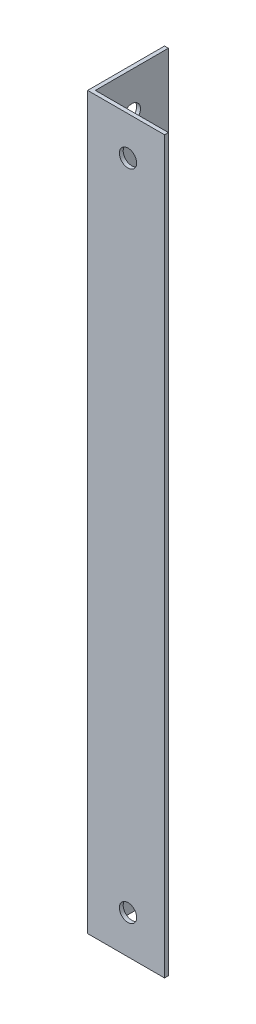
from build123d import *

# Parameters (mm, degrees)
EXTRUDE_1_DEPTH     = 190
SKETCH_2_R          = 2.25
CUT_EXTRUDE_1_DEPTH = 2
SKETCH_3_R          = 2.25
CUT_EXTRUDE_2_DEPTH = 2


with BuildPart() as part:
    # Эскиз1 → Бобышка-Вытянуть1 (new body)
    with BuildSketch(Plane(origin=(0, 0, 0), x_dir=(1, 0, 0), z_dir=(0, 1, 0))):
        Polygon((0, 0), (0, 20), (1, 20), (1, 1), (20, 1), (20, 0), align=None)
    extrude(amount=EXTRUDE_1_DEPTH)

    # Эскиз2 → Вырез-Вытянуть1 (cut, through all)
    with BuildSketch(Plane(origin=(1, 0, 0), x_dir=(0, 0, -1), z_dir=(1, 0, 0))):
        with Locations((10.5, 10)):
            Circle(SKETCH_2_R)
        with Locations((10.5, 180)):
            Circle(SKETCH_2_R)
    extrude(amount=-CUT_EXTRUDE_1_DEPTH, mode=Mode.SUBTRACT)

    # Эскиз3 → Вырез-Вытянуть2 (cut, through all)
    with BuildSketch(Plane(origin=(0, 0, -1), x_dir=(-1, 0, 0), z_dir=(0, 0, -1))):
        with Locations((-10.5, 180)):
            Circle(SKETCH_3_R)
        with Locations((-10.5, 10)):
            Circle(SKETCH_3_R)
    extrude(amount=-CUT_EXTRUDE_2_DEPTH, mode=Mode.SUBTRACT)


solid = part.part
